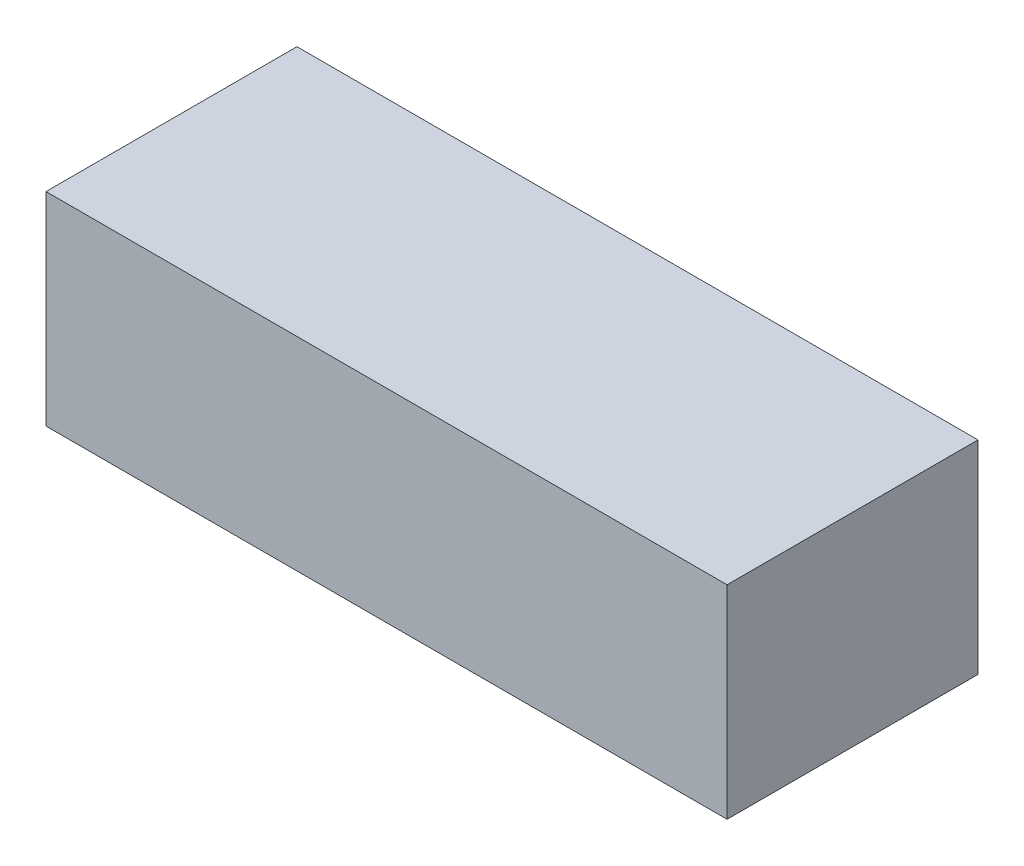
from build123d import *

# Parameters (mm, degrees)
CROQUIS1_W              = 57.000000029
CROQUIS1_H              = 20.999999717
SALIENTE_EXTRUIR1_DEPTH = 16.999999993
CROQUIS2_W              = 55.000001564
CROQUIS2_H              = 11.000000872
SALIENTE_EXTRUIR2_DEPTH = 1.000000164
CROQUIS3_W              = 52.999999375
CROQUIS3_H              = 3.000000492
SALIENTE_EXTRUIR3_DEPTH = 0.999999233


with BuildPart() as part:
    # Croquis1 → Saliente-Extruir1 (new body)
    with BuildSketch(Plane(origin=(0, 9.999999776, 0), x_dir=(1, 0, 0), z_dir=(0, 1, 0))):
        with Locations((17.500000075, -10.499999859)):
            Rectangle(CROQUIS1_W, CROQUIS1_H)
    extrude(amount=-SALIENTE_EXTRUIR1_DEPTH)

    # Croquis2 → Saliente-Extruir2 (add)
    with BuildSketch(Plane.XZ.offset(7.000000216)):
        with Locations((17.500001006, 10.500000324)):
            Rectangle(CROQUIS2_W, CROQUIS2_H)
    extrude(amount=SALIENTE_EXTRUIR2_DEPTH)

    # Croquis3 → Saliente-Extruir3 (add)
    with BuildSketch(Plane.XZ.offset(8.00000038)):
        with Locations((17.500000075, 11.500000022)):
            Rectangle(CROQUIS3_W, CROQUIS3_H)
    extrude(amount=SALIENTE_EXTRUIR3_DEPTH)


solid = part.part
